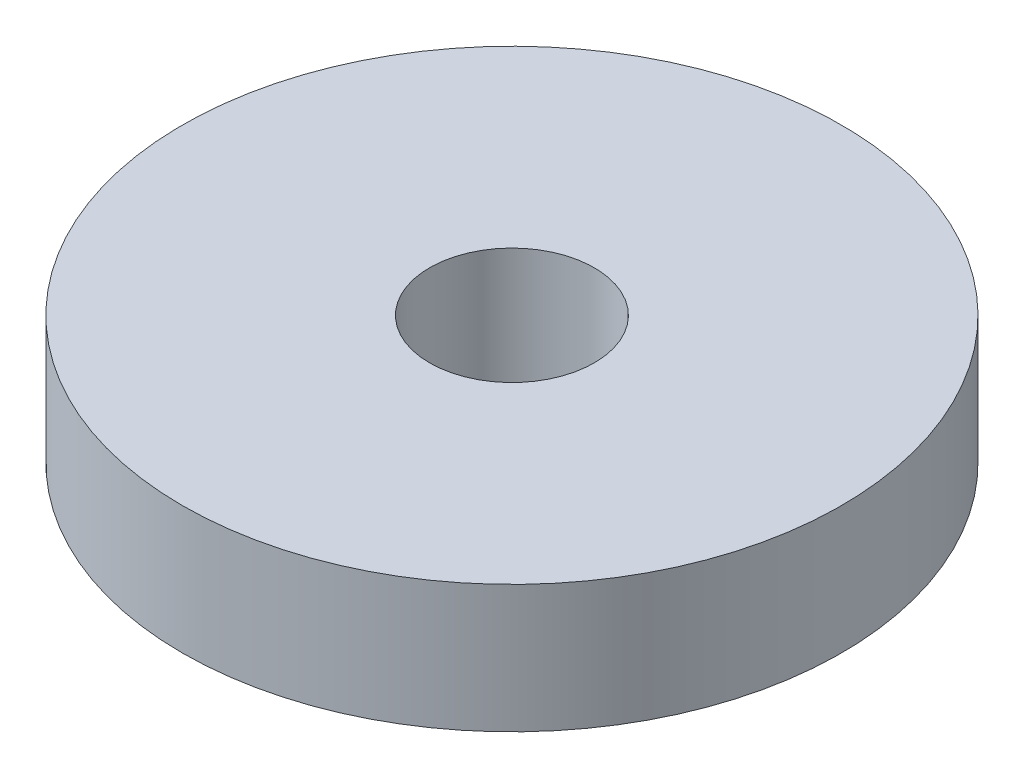
from build123d import *

# Parameters (mm, degrees)
SKETCH1_R           = 10.16
SKETCH1_R_2         = 2.54
BOSS_EXTRUDE1_DEPTH = 3.937


with BuildPart() as part:
    # Sketch1 → Boss-Extrude1 (new body)
    with BuildSketch(Plane(origin=(0, 0, 0), x_dir=(1, 0, 0), z_dir=(0, 1, 0))):
        Circle(SKETCH1_R)
        Circle(SKETCH1_R_2, mode=Mode.SUBTRACT)
    extrude(amount=BOSS_EXTRUDE1_DEPTH)


solid = part.part
